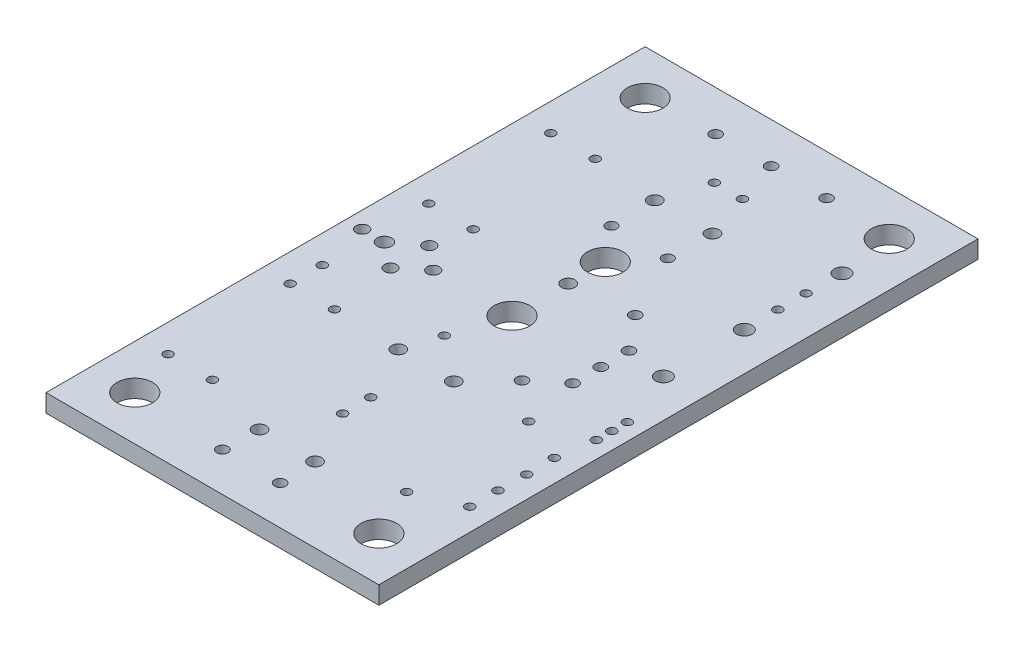
from build123d import *

# Parameters (mm, degrees)
ESQUISSE2_W      = 30
ESQUISSE2_H      = 54
ESQUISSE2_R      = 0.59944
ESQUISSE2_R_2    = 1.6002
ESQUISSE2_R_3    = 0.50038
ESQUISSE2_R_4    = 0.4826
ESQUISSE2_R_5    = 0.39878
ESQUISSE2_R_6    = 0.55118
ESQUISSE2_R_7    = 0.65024
ESQUISSE2_R_8    = 0.70104
EXTRUSION1_DEPTH = 1.6


with BuildPart() as part:
    # Esquisse2 → Extrusion1 (new body)
    with BuildSketch(Plane(origin=(0, 0, 0), x_dir=(1, 0, 0), z_dir=(0, 1, 0))):
        with Locations((15, 27)):
            Rectangle(ESQUISSE2_W, ESQUISSE2_H)
        with Locations(Location((17.62252, 42.44594, 0), (0, 0, 270))):  # turned: the seam where the file's is
            Circle(ESQUISSE2_R, mode=Mode.SUBTRACT)
        with Locations(Location((12.4206, 42.44594, 0), (0, 0, 270))):  # turned: the seam where the file's is
            Circle(ESQUISSE2_R, mode=Mode.SUBTRACT)
        with Locations(Location((15.02156, 32.04464, 0), (0, 0, 270))):  # turned: the seam where the file's is
            Circle(ESQUISSE2_R, mode=Mode.SUBTRACT)
        with Locations(Location((15.00378, 35.40252, 0), (0, 0, 270))):  # turned: the seam where the file's is
            Circle(ESQUISSE2_R_2, mode=Mode.SUBTRACT)
        with Locations(Location((17.59966, 3.50012, 0), (0, 0, 270))):  # turned: the seam where the file's is
            Circle(ESQUISSE2_R_3, mode=Mode.SUBTRACT)
        with Locations(Location((12.40028, 3.50012, 0), (0, 0, 270))):  # turned: the seam where the file's is
            Circle(ESQUISSE2_R_3, mode=Mode.SUBTRACT)
        with Locations(Location((15.00124, 50.35042, 0), (0, 0, 270))):  # turned: the seam where the file's is
            Circle(ESQUISSE2_R_3, mode=Mode.SUBTRACT)
        with Locations(Location((19.99996, 50.35042, 0), (0, 0, 270))):  # turned: the seam where the file's is
            Circle(ESQUISSE2_R_3, mode=Mode.SUBTRACT)
        with Locations(Location((9.99998, 50.35042, 0), (0, 0, 270))):  # turned: the seam where the file's is
            Circle(ESQUISSE2_R_3, mode=Mode.SUBTRACT)
        with Locations(Location((12.49934, 19.25066, 0), (0, 0, 270))):  # turned: the seam where the file's is
            Circle(ESQUISSE2_R, mode=Mode.SUBTRACT)
        with Locations(Location((12.49934, 6.74878, 0), (0, 0, 270))):  # turned: the seam where the file's is
            Circle(ESQUISSE2_R, mode=Mode.SUBTRACT)
        with Locations(Location((17.5006, 19.25066, 0), (0, 0, 270))):  # turned: the seam where the file's is
            Circle(ESQUISSE2_R, mode=Mode.SUBTRACT)
        with Locations(Location((17.5006, 6.74878, 0), (0, 0, 270))):  # turned: the seam where the file's is
            Circle(ESQUISSE2_R, mode=Mode.SUBTRACT)
        with Locations(Location((20.50034, 22.40026, 0), (0, 0, 270))):  # turned: the seam where the file's is
            Circle(ESQUISSE2_R_3, mode=Mode.SUBTRACT)
        with Locations(Location((20.50034, 32.6009, 0), (0, 0, 270))):  # turned: the seam where the file's is
            Circle(ESQUISSE2_R_3, mode=Mode.SUBTRACT)
        with Locations(Location((12.46124, 38.49878, 0), (0, 0, 270))):  # turned: the seam where the file's is
            Circle(ESQUISSE2_R_4, mode=Mode.SUBTRACT)
        with Locations(Location((17.54124, 38.49878, 0), (0, 0, 270))):  # turned: the seam where the file's is
            Circle(ESQUISSE2_R_4, mode=Mode.SUBTRACT)
        with Locations(Location((16.27124, 46.49978, 0), (0, 0, 270))):  # turned: the seam where the file's is
            Circle(ESQUISSE2_R_5, mode=Mode.SUBTRACT)
        with Locations(Location((13.73124, 46.49978, 0), (0, 0, 270))):  # turned: the seam where the file's is
            Circle(ESQUISSE2_R_5, mode=Mode.SUBTRACT)
        with Locations(Location((15.00124, 11.72972, 0), (0, 0, 270))):  # turned: the seam where the file's is
            Circle(ESQUISSE2_R_5, mode=Mode.SUBTRACT)
        with Locations(Location((15.00124, 14.26972, 0), (0, 0, 270))):  # turned: the seam where the file's is
            Circle(ESQUISSE2_R_5, mode=Mode.SUBTRACT)
        with Locations(Location((1.4986, 27.0002, 0), (0, 0, 270))):  # turned: the seam where the file's is
            Circle(ESQUISSE2_R_6, mode=Mode.SUBTRACT)
        with Locations(Location((7.8994, 27.0002, 0), (0, 0, 270))):  # turned: the seam where the file's is
            Circle(ESQUISSE2_R_6, mode=Mode.SUBTRACT)
        with Locations(Location((5.79882, 25.25014, 0), (0, 0, 270))):  # turned: the seam where the file's is
            Circle(ESQUISSE2_R_6, mode=Mode.SUBTRACT)
        with Locations(Location((5.79882, 28.75026, 0), (0, 0, 270))):  # turned: the seam where the file's is
            Circle(ESQUISSE2_R_6, mode=Mode.SUBTRACT)
        with Locations(Location((3.50012, 27.0002, 0), (0, 0, 270))):  # turned: the seam where the file's is
            Circle(ESQUISSE2_R_7, mode=Mode.SUBTRACT)
        with Locations(Location((4.0005, 49.9999, 0), (0, 0, 270))):  # turned: the seam where the file's is
            Circle(ESQUISSE2_R_2, mode=Mode.SUBTRACT)
        with Locations(Location((25.99944, 49.9999, 0), (0, 0, 270))):  # turned: the seam where the file's is
            Circle(ESQUISSE2_R_2, mode=Mode.SUBTRACT)
        with Locations(Location((4.0005, 4.0005, 0), (0, 0, 270))):  # turned: the seam where the file's is
            Circle(ESQUISSE2_R_2, mode=Mode.SUBTRACT)
        with Locations(Location((15.00124, 27.0002, 0), (0, 0, 270))):  # turned: the seam where the file's is
            Circle(ESQUISSE2_R_2, mode=Mode.SUBTRACT)
        with Locations(Location((25.99944, 4.0005, 0), (0, 0, 270))):  # turned: the seam where the file's is
            Circle(ESQUISSE2_R_2, mode=Mode.SUBTRACT)
        with Locations(Location((22.9997, 24.4602, 0), (0, 0, 270))):  # turned: the seam where the file's is
            Circle(ESQUISSE2_R_3, mode=Mode.SUBTRACT)
        with Locations(Location((22.9997, 27.0002, 0), (0, 0, 270))):  # turned: the seam where the file's is
            Circle(ESQUISSE2_R_3, mode=Mode.SUBTRACT)
        with Locations(Location((22.9997, 29.5402, 0), (0, 0, 270))):  # turned: the seam where the file's is
            Circle(ESQUISSE2_R_3, mode=Mode.SUBTRACT)
        with Locations(Location((28.04922, 15.27048, 0), (0, 0, 270))):  # turned: the seam where the file's is
            Circle(ESQUISSE2_R_5, mode=Mode.SUBTRACT)
        with Locations(Location((28.00096, 12.73048, 0), (0, 0, 270))):  # turned: the seam where the file's is
            Circle(ESQUISSE2_R_5, mode=Mode.SUBTRACT)
        with Locations(Location((28.00096, 10.19048, 0), (0, 0, 270))):  # turned: the seam where the file's is
            Circle(ESQUISSE2_R_5, mode=Mode.SUBTRACT)
        with Locations(Location((28.00096, 17.81048, 0), (0, 0, 270))):  # turned: the seam where the file's is
            Circle(ESQUISSE2_R_5, mode=Mode.SUBTRACT)
        with Locations(Location((26.49982, 41.9989, 0), (0, 0, 270))):  # turned: the seam where the file's is
            Circle(ESQUISSE2_R_5, mode=Mode.SUBTRACT)
        with Locations(Location((26.49982, 39.4589, 0), (0, 0, 270))):  # turned: the seam where the file's is
            Circle(ESQUISSE2_R_5, mode=Mode.SUBTRACT)
        with Locations(Location((26.56078, 45.17898, 0), (0, 0, 270))):  # turned: the seam where the file's is
            Circle(ESQUISSE2_R_8, mode=Mode.SUBTRACT)
        with Locations(Location((26.56078, 36.38042, 0), (0, 0, 270))):  # turned: the seam where the file's is
            Circle(ESQUISSE2_R_8, mode=Mode.SUBTRACT)
        with Locations(Location((26.56078, 29.08046, 0), (0, 0, 270))):  # turned: the seam where the file's is
            Circle(ESQUISSE2_R_8, mode=Mode.SUBTRACT)
        with Locations(Location((24.00046, 8.49884, 0), (0, 0, 270))):  # turned: the seam where the file's is
            Circle(ESQUISSE2_R_5, mode=Mode.SUBTRACT)
        with Locations(Location((24.00046, 19.49958, 0), (0, 0, 270))):  # turned: the seam where the file's is
            Circle(ESQUISSE2_R_5, mode=Mode.SUBTRACT)
        with Locations(Location((6.49986, 42.99966, 0), (0, 0, 270))):  # turned: the seam where the file's is
            Circle(ESQUISSE2_R_5, mode=Mode.SUBTRACT)
        with Locations(Location((6.49986, 31.99892, 0), (0, 0, 270))):  # turned: the seam where the file's is
            Circle(ESQUISSE2_R_5, mode=Mode.SUBTRACT)
        with Locations(Location((2.49936, 42.99966, 0), (0, 0, 270))):  # turned: the seam where the file's is
            Circle(ESQUISSE2_R_5, mode=Mode.SUBTRACT)
        with Locations(Location((2.49936, 31.99892, 0), (0, 0, 270))):  # turned: the seam where the file's is
            Circle(ESQUISSE2_R_5, mode=Mode.SUBTRACT)
        with Locations(Location((6.49986, 8.49884, 0), (0, 0, 270))):  # turned: the seam where the file's is
            Circle(ESQUISSE2_R_5, mode=Mode.SUBTRACT)
        with Locations(Location((6.49986, 19.49958, 0), (0, 0, 270))):  # turned: the seam where the file's is
            Circle(ESQUISSE2_R_5, mode=Mode.SUBTRACT)
        with Locations(Location((2.49936, 8.49884, 0), (0, 0, 270))):  # turned: the seam where the file's is
            Circle(ESQUISSE2_R_5, mode=Mode.SUBTRACT)
        with Locations(Location((2.49936, 19.49958, 0), (0, 0, 270))):  # turned: the seam where the file's is
            Circle(ESQUISSE2_R_5, mode=Mode.SUBTRACT)
        with Locations(Location((2.49936, 22.40026, 0), (0, 0, 270))):  # turned: the seam where the file's is
            Circle(ESQUISSE2_R_5, mode=Mode.SUBTRACT)
        with Locations(Location((13.5001, 22.40026, 0), (0, 0, 270))):  # turned: the seam where the file's is
            Circle(ESQUISSE2_R_5, mode=Mode.SUBTRACT)
        with Locations(Location((28.4988, 21.09978, 0), (0, 0, 270))):  # turned: the seam where the file's is
            Circle(ESQUISSE2_R_5, mode=Mode.SUBTRACT)
        with Locations(Location((28.4988, 22.49932, 0), (0, 0, 270))):  # turned: the seam where the file's is
            Circle(ESQUISSE2_R_5, mode=Mode.SUBTRACT)
        with Locations(Location((28.4988, 23.89886, 0), (0, 0, 270))):  # turned: the seam where the file's is
            Circle(ESQUISSE2_R_5, mode=Mode.SUBTRACT)
    extrude(amount=EXTRUSION1_DEPTH)


solid = part.part
